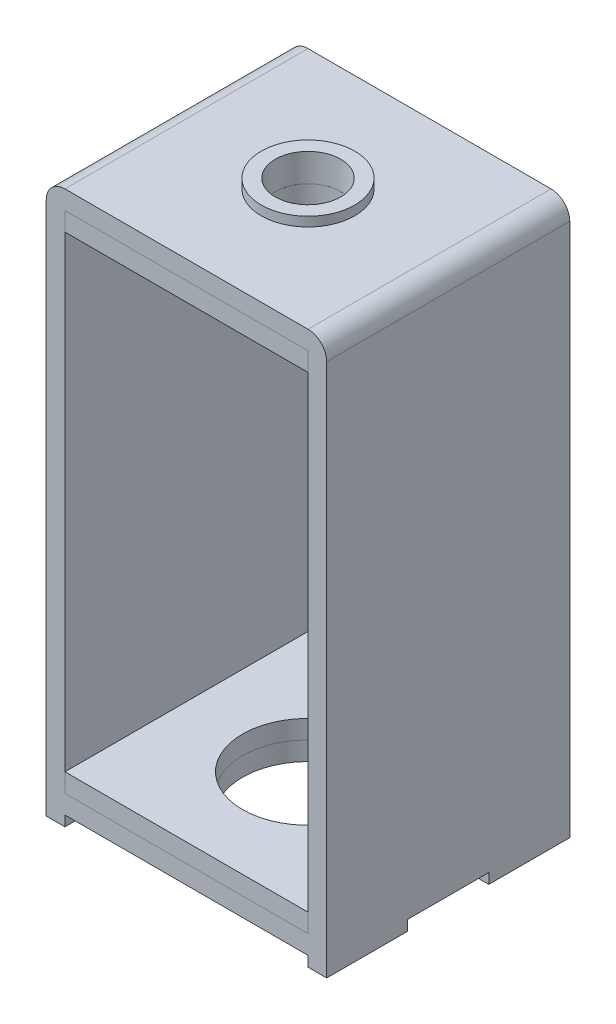
from build123d import *

# Parameters (mm, degrees)
SKETCH1_W           = 15
SKETCH1_H           = 13
BOSS_EXTRUDE1_DEPTH = 1
SKETCH2_W           = 1
SKETCH2_H           = 13
BOSS_EXTRUDE2_DEPTH = 27
SKETCH3_W           = 15
SKETCH3_H           = 13
BOSS_EXTRUDE3_DEPTH = 1
FILLET1_R           = 1
FILLET2_R           = 1
SKETCH4_W           = 1
SKETCH4_H           = 4.33
BOSS_EXTRUDE4_DEPTH = 0.55
SKETCH5_W           = 13
SKETCH5_H           = 13
BOSS_EXTRUDE5_DEPTH = 1
SKETCH7_W           = 13
SKETCH7_H           = 13
BOSS_EXTRUDE6_DEPTH = 1
SKETCH8_R           = 3.5
CUT_EXTRUDE1_DEPTH  = 3.55
SKETCH9_R           = 1.75
CUT_EXTRUDE2_DEPTH  = 3
SKETCH10_R          = 2.5
SKETCH10_R_2        = 1.75
BOSS_EXTRUDE7_DEPTH = 0.5


with BuildPart() as part:
    # Sketch1 → Boss-Extrude1 (new body)
    with BuildSketch(Plane(origin=(0, 0, 0), x_dir=(1, 0, 0), z_dir=(0, 1, 0))):
        with Locations((1.602439024, 0.031707317)):
            Rectangle(SKETCH1_W, SKETCH1_H)
    extrude(amount=BOSS_EXTRUDE1_DEPTH)

    # Sketch2 → Boss-Extrude2 (add)
    with BuildSketch(Plane(origin=(0, 1, 0), x_dir=(1, 0, 0), z_dir=(0, 1, 0))):
        with Locations((-5.397560976, 0.031707317)):
            Rectangle(SKETCH2_W, SKETCH2_H)
        with Locations((8.602439024, 0.031707317)):
            Rectangle(SKETCH2_W, SKETCH2_H)
    extrude(amount=BOSS_EXTRUDE2_DEPTH)

    # Sketch3 → Boss-Extrude3 (add)
    with BuildSketch(Plane(origin=(0, 28, 0), x_dir=(1, 0, 0), z_dir=(0, 1, 0))):
        with Locations((1.602439024, 0.031707317)):
            Rectangle(SKETCH3_W, SKETCH3_H)
    extrude(amount=BOSS_EXTRUDE3_DEPTH)

    # Fillet1
    fillet1_edges = [part.edges().sort_by_distance(p)[0] for p in [
        (-5.897560976, 29, -0.031707317),
    ]]
    fillet(fillet1_edges, radius=FILLET1_R)

    # Fillet2
    fillet2_edges = [part.edges().sort_by_distance(p)[0] for p in [
        (9.102439024, 29, -0.031707317),
    ]]
    fillet(fillet2_edges, radius=FILLET2_R)

    # Sketch4 → Boss-Extrude4 (add)
    with BuildSketch(Plane.XZ):
        with Locations((-5.397560976, 4.303292683)):
            Rectangle(SKETCH4_W, SKETCH4_H)
        with Locations((8.602439024, 4.303292683)):
            Rectangle(SKETCH4_W, SKETCH4_H)
        with Locations((-5.397560976, -4.366707317)):
            Rectangle(SKETCH4_W, SKETCH4_H)
        with Locations((8.602439024, -4.366707317)):
            Rectangle(SKETCH4_W, SKETCH4_H)
    extrude(amount=BOSS_EXTRUDE4_DEPTH)


with BuildPart() as body_2:
    # Sketch5 → Boss-Extrude5 (new body)
    with BuildSketch(Plane(origin=(0, 1, 0), x_dir=(1, 0, 0), z_dir=(0, 1, 0))):
        with Locations((1.602439024, 0.031707317)):
            Rectangle(SKETCH5_W, SKETCH5_H)
    extrude(amount=BOSS_EXTRUDE5_DEPTH)


with BuildPart() as body_3:
    # Sketch7 → Boss-Extrude6 (new body)
    with BuildSketch(Plane.XZ.offset(-28)):
        with Locations((1.602439024, -0.031707317)):
            Rectangle(SKETCH7_W, SKETCH7_H)
    extrude(amount=BOSS_EXTRUDE6_DEPTH)


with BuildPart() as cut_extrude1_tool:
    # Sketch8 → Cut-Extrude1 (new body, through all)
    with BuildSketch(Plane(origin=(0, 2, 0), x_dir=(1, 0, 0), z_dir=(0, 1, 0))):
        with Locations((1.602439024, 0.031707317)):
            Circle(SKETCH8_R)
    extrude(amount=-CUT_EXTRUDE1_DEPTH)


with BuildPart() as part_1:
    add(part.part)

    # Cut-Extrude1: cut by cut_extrude1_tool
    add(cut_extrude1_tool.part, mode=Mode.SUBTRACT)


with BuildPart() as body_2_1:
    add(body_2.part)

    # Cut-Extrude1: cut by cut_extrude1_tool
    add(cut_extrude1_tool.part, mode=Mode.SUBTRACT)


with BuildPart() as cut_extrude2_tool:
    # Sketch9 → Cut-Extrude2 (new body, through all)
    with BuildSketch(Plane.XZ.offset(-27)):
        with Locations((1.602439024, -0.031707317)):
            Circle(SKETCH9_R)
    extrude(amount=-CUT_EXTRUDE2_DEPTH)


with BuildPart() as part_2:
    add(part_1.part)

    # Cut-Extrude2: cut by cut_extrude2_tool
    add(cut_extrude2_tool.part, mode=Mode.SUBTRACT)

    # Sketch10 → Boss-Extrude7 (add)
    with BuildSketch(Plane(origin=(0, 29, 0), x_dir=(1, 0, 0), z_dir=(0, 1, 0))):
        with Locations((1.602439024, 0.031707317)):
            Circle(SKETCH10_R)
        with Locations((1.602439024, 0.031707317)):
            Circle(SKETCH10_R_2, mode=Mode.SUBTRACT)
    extrude(amount=BOSS_EXTRUDE7_DEPTH)


with BuildPart() as body_3_1:
    add(body_3.part)

    # Cut-Extrude2: cut by cut_extrude2_tool
    add(cut_extrude2_tool.part, mode=Mode.SUBTRACT)


solid = Compound([body_2_1.part, part_2.part, body_3_1.part])
